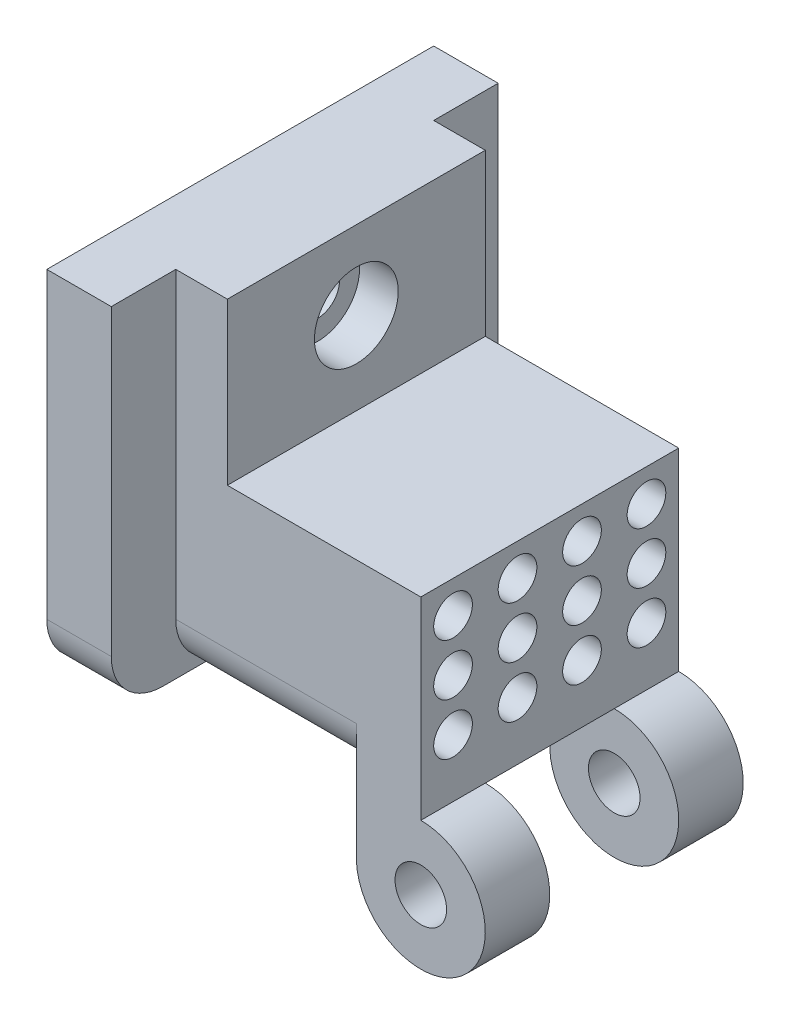
from build123d import *

# Parameters (mm, degrees)
SKETCH1_W                      = 20
SKETCH1_H                      = 15
BOSS_EXTRUDE1_DEPTH            = 15
SKETCH2_R                      = 2
BOSS_EXTRUDE2_DEPTH            = 5
BOSS_EXTRUDE3_DEPTH            = 15
BOSS_EXTRUDE3_DEPTH_BACK       = 12.5
FILLET1_R                      = 4
M3X0_5_TAPPED_HOLE1_D          = 2.5
M3X0_5_TAPPED_HOLE1_DEPTH      = 11
M3X0_5_TAPPED_HOLE1_TIP        = 0.751075774
CBORE_FOR_M3_SHCS1_D           = 3.4
CBORE_FOR_M3_SHCS1_DEPTH       = 9
CBORE_FOR_M3_SHCS1_CBORE_D     = 6.5
CBORE_FOR_M3_SHCS1_CBORE_DEPTH = 3
CBORE_FOR_M3_SHCS1_TIP         = 1.021463052
SKETCH8_R                      = 1.5
CUT_EXTRUDE1_DEPTH             = 2.5


with BuildPart() as part:
    # Sketch1 → Boss-Extrude1 (new body)
    with BuildSketch(Plane(origin=(0, 0, 0), x_dir=(0, 0, -1), z_dir=(1, 0, 0))):
        Rectangle(SKETCH1_W, SKETCH1_H)
    extrude(amount=BOSS_EXTRUDE1_DEPTH)

    # Sketch2 → Boss-Extrude2 (add)
    with BuildSketch(Plane.XY.offset(10)):
        with BuildLine():
            Line((15, -7.5), (10.015567122, -7.5))
            Line((10.015567122, -7.5), (10.015567122, -12.105755295))
            ThreePointArc((10.015567122, -12.105755295), (18.393285758, -16.172276101), (15, -7.5))
        make_face()
        with Locations((15, -12.5)):
            Circle(SKETCH2_R, mode=Mode.SUBTRACT)
    boss_extrude2 = extrude(amount=-BOSS_EXTRUDE2_DEPTH)

    # Mirror1: Boss-Extrude2 across plane
    add(boss_extrude2.mirror(Plane.XY))

    # Sketch3 → Boss-Extrude3 (add, two sides)
    with BuildSketch(Plane.XZ.offset(-7.5)) as boss_extrude3_sk:
        Polygon((-4, 10), (-4, 15), (-9, 15), (-9, -15), (-4, -15), (-4, -10), (0, -10), (0, 10), align=None)
    extrude(amount=BOSS_EXTRUDE3_DEPTH)
    extrude(boss_extrude3_sk.sketch, amount=-BOSS_EXTRUDE3_DEPTH_BACK)

    # Fillet1
    fillet1_edges = [part.edges().sort_by_distance(p)[0] for p in [
        (3.007783561, -7.5, 10),
        (3.007783561, -7.5, -10),
        (-6.5, -7.5, -15),
        (-6.5, -7.5, 15),
    ]]
    fillet(fillet1_edges, radius=FILLET1_R)

    # M3x0.5 Tapped Hole1
    with Locations(Plane(origin=(0, 0, 0), x_dir=(0, 0, -1), z_dir=(1, 0, 0))):
        with Locations((0, 13.90875121)):
            Hole(M3X0_5_TAPPED_HOLE1_D / 2, depth=M3X0_5_TAPPED_HOLE1_DEPTH)
            with Locations((0, 0, -(M3X0_5_TAPPED_HOLE1_DEPTH + M3X0_5_TAPPED_HOLE1_TIP / 2))):  # 118° drill point
                Cone(0, M3X0_5_TAPPED_HOLE1_D / 2, M3X0_5_TAPPED_HOLE1_TIP, mode=Mode.SUBTRACT)

    # CBORE for M3 SHCS1
    with Locations(Plane(origin=(0, 0, 0), x_dir=(0, 0, -1), z_dir=(1, 0, 0))):
        with Locations((0, 13.90875121)):
            CounterBoreHole(CBORE_FOR_M3_SHCS1_D / 2, CBORE_FOR_M3_SHCS1_CBORE_D / 2, CBORE_FOR_M3_SHCS1_CBORE_DEPTH, depth=CBORE_FOR_M3_SHCS1_DEPTH)
            with Locations((0, 0, -(CBORE_FOR_M3_SHCS1_DEPTH + CBORE_FOR_M3_SHCS1_TIP / 2))):  # 118° drill point
                Cone(0, CBORE_FOR_M3_SHCS1_D / 2, CBORE_FOR_M3_SHCS1_TIP, mode=Mode.SUBTRACT)

    # Sketch8 → Cut-Extrude1 (cut)
    with BuildSketch(Plane(origin=(15, 0, 0), x_dir=(0, 0, -1), z_dir=(1, 0, 0))):
        with Locations((-7.5, 5)):
            Circle(SKETCH8_R)
        with Locations((-2.5, 5)):
            Circle(SKETCH8_R)
        with Locations((2.5, 5)):
            Circle(SKETCH8_R)
        with Locations((7.5, 5)):
            Circle(SKETCH8_R)
        with Locations((-2.5, 1)):
            Circle(SKETCH8_R)
        with Locations((2.5, 1)):
            Circle(SKETCH8_R)
        with Locations((7.5, 1)):
            Circle(SKETCH8_R)
        with Locations((-2.5, -3)):
            Circle(SKETCH8_R)
        with Locations((2.5, -3)):
            Circle(SKETCH8_R)
        with Locations((7.5, -3)):
            Circle(SKETCH8_R)
        with Locations((-7.5, 1)):
            Circle(SKETCH8_R)
        with Locations((-7.5, -3)):
            Circle(SKETCH8_R)
    extrude(amount=-CUT_EXTRUDE1_DEPTH, mode=Mode.SUBTRACT)


solid = part.part
